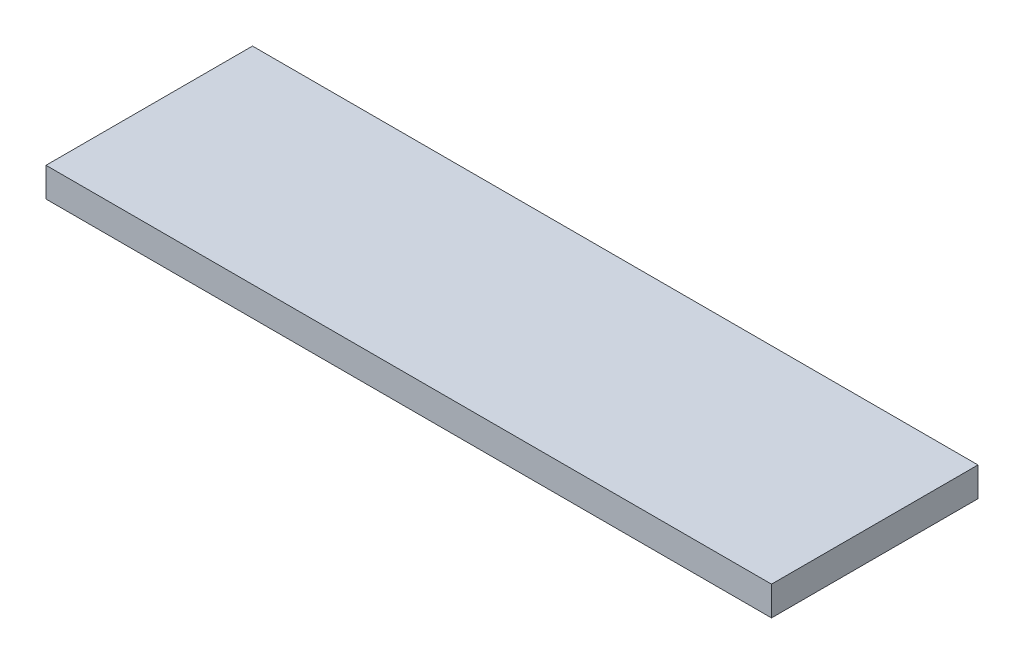
from build123d import *

# Parameters (mm, degrees)
ESQUISSE1_W        = 61.960694999
ESQUISSE1_H        = 17.634967038
BOSS_EXTRU_1_DEPTH = 2.5


with BuildPart() as part:
    # Esquisse1 → Boss.-Extru.1 (new body)
    with BuildSketch(Plane(origin=(0, 0, 0), x_dir=(1, 0, 0), z_dir=(0, 1, 0))):
        with Locations((-8.221707605, 15.013553019)):
            Rectangle(ESQUISSE1_W, ESQUISSE1_H)
    extrude(amount=BOSS_EXTRU_1_DEPTH)


solid = part.part
